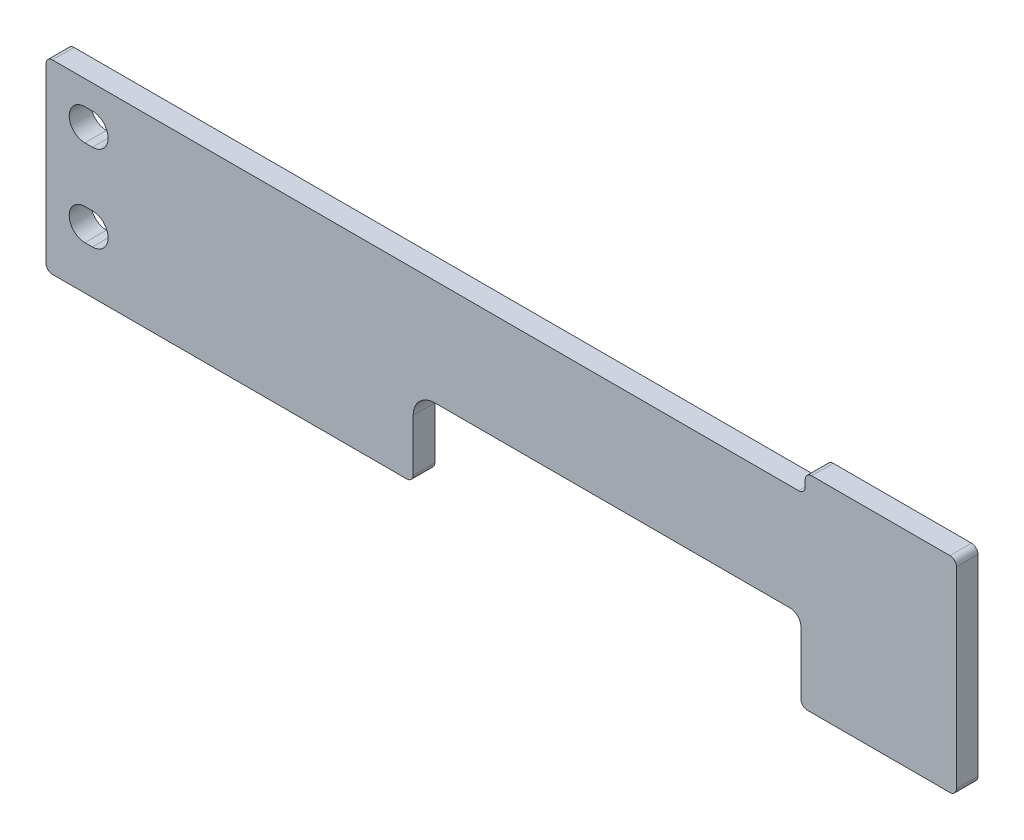
from build123d import *

# Parameters (mm, degrees)
EXTRUDE1_DEPTH = 10


with BuildPart() as part:
    # Sketch1 → Extrude1 (new body)
    with BuildSketch(Plane.XY):
        with BuildLine():
            Line((-3, 0), (-67, 0))
            ThreePointArc((-67, 0), (-69.121320344, -0.878679656), (-70, -3))
            Line((-70, -3), (-70, -6))
            ThreePointArc((-70, -6), (-70.878679656, -8.121320344), (-73, -9))
            Line((-73, -9), (-418.5, -9))
            ThreePointArc((-418.5, -9), (-420.621320344, -9.878679656), (-421.5, -12))
            Line((-421.5, -12), (-421.5, -92))
            ThreePointArc((-421.5, -92), (-420.621320344, -94.121320344), (-418.5, -95))
            Line((-418.5, -95), (-254.5, -95))
            ThreePointArc((-254.5, -95), (-252.378679656, -94.121320344), (-251.5, -92))
            Line((-251.5, -92), (-251.5, -68))
            ThreePointArc((-251.5, -68), (-248.571067812, -60.928932188), (-241.5, -58))
            Line((-241.5, -58), (-77, -58))
            ThreePointArc((-77, -58), (-73.464466094, -59.464466094), (-72, -63))
            Line((-72, -63), (-72, -92))
            ThreePointArc((-72, -92), (-71.121320344, -94.121320344), (-69, -95))
            Line((-69, -95), (-3, -95))
            ThreePointArc((-3, -95), (-0.878679656, -94.121320344), (0, -92))
            Line((0, -92), (0, -3))
            ThreePointArc((0, -3), (-0.878679656, -0.878679656), (-3, 0))
        make_face()
        with BuildLine():
            Line((-403.5, -74.75), (-400, -74.75))
            ThreePointArc((-400, -74.75), (-392.75, -67.5), (-400, -60.25))
            Line((-400, -60.25), (-403.5, -60.25))
            ThreePointArc((-403.5, -60.25), (-410.75, -67.5), (-403.5, -74.75))
        make_face(mode=Mode.SUBTRACT)
        with BuildLine():
            Line((-403.5, -34.75), (-400, -34.75))
            ThreePointArc((-400, -34.75), (-392.75, -27.5), (-400, -20.25))
            Line((-400, -20.25), (-403.5, -20.25))
            ThreePointArc((-403.5, -20.25), (-410.75, -27.5), (-403.5, -34.75))
        make_face(mode=Mode.SUBTRACT)
    extrude(amount=EXTRUDE1_DEPTH)


solid = part.part
